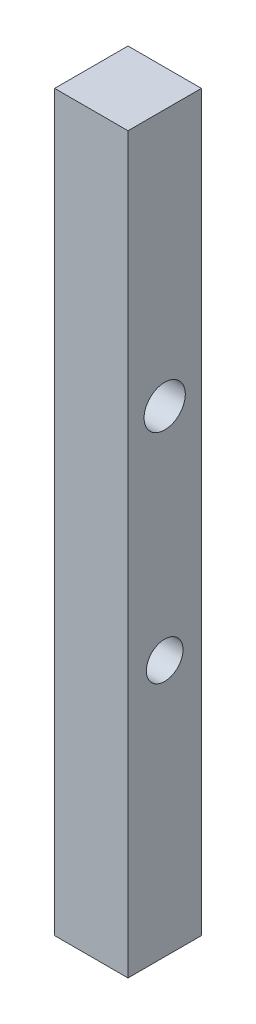
from build123d import *

# Parameters (mm, degrees)
SKETCH1_W           = 25.4
SKETCH1_H           = 25.4
BOSS_EXTRUDE1_DEPTH = 254
SKETCH2_R           = 7.139293869
SKETCH2_R_2         = 6.35
CUT_EXTRUDE1_DEPTH  = 26.4


with BuildPart() as part:
    # Sketch1 → Boss-Extrude1 (new body)
    with BuildSketch(Plane(origin=(0, 0, 0), x_dir=(1, 0, 0), z_dir=(0, 1, 0))):
        with Locations((-12.7, 12.7)):
            Rectangle(SKETCH1_W, SKETCH1_H)
    extrude(amount=BOSS_EXTRUDE1_DEPTH)

    # Sketch2 → Cut-Extrude1 (cut, through all)
    with BuildSketch(Plane(origin=(0, 0, 0), x_dir=(0, 0, -1), z_dir=(1, 0, 0))):
        with Locations((12.7, 165.1)):
            Circle(SKETCH2_R)
        with Locations((12.7, 88.9)):
            Circle(SKETCH2_R_2)
    extrude(amount=-CUT_EXTRUDE1_DEPTH, mode=Mode.SUBTRACT)


solid = part.part
